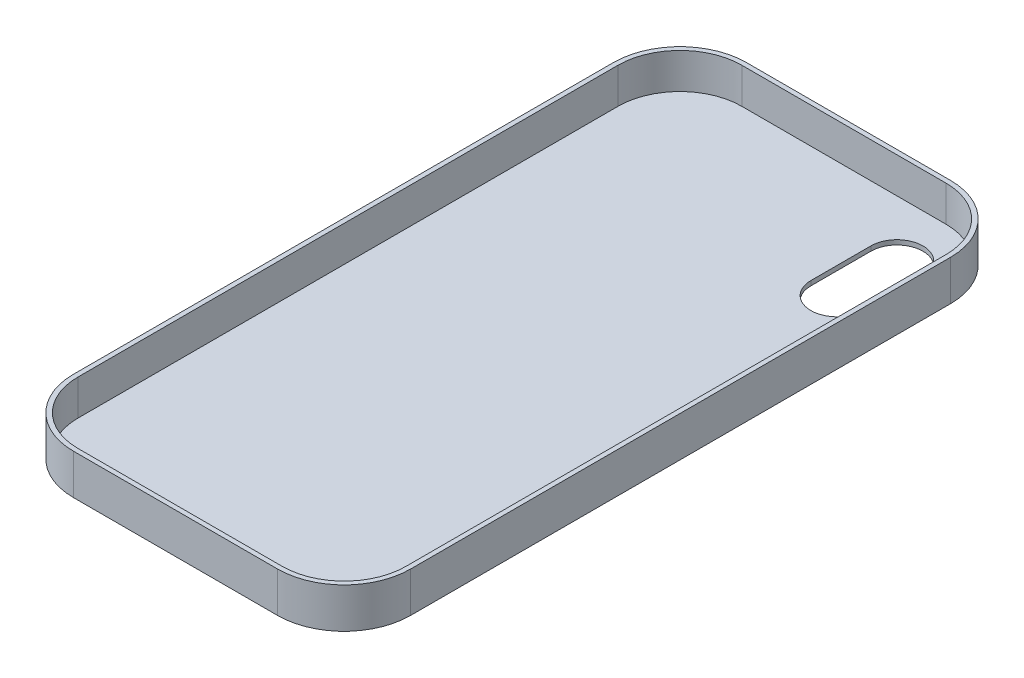
from build123d import *

# Parameters (mm, degrees)
BOSS_EXTRUDE1_DEPTH = 8.7
CUT_EXTRUDE1_DEPTH  = 7.7
CUT_EXTRUDE2_DEPTH  = 2


with BuildPart() as part:
    # Sketch1 → Boss-Extrude1 (new body)
    with BuildSketch(Plane(origin=(0, 0, 0), x_dir=(1, 0, 0), z_dir=(0, 1, 0))):
        with BuildLine():
            Line((-22.08, -72.785), (22.08, -72.785))
            ThreePointArc((22.08, -72.785), (32.255266581, -68.570266581), (36.47, -58.395))
            Line((36.47, -58.395), (36.47, 58.395))
            ThreePointArc((36.47, 58.395), (32.255266581, 68.570266581), (22.08, 72.785))
            Line((22.08, 72.785), (-22.08, 72.785))
            ThreePointArc((-22.08, 72.785), (-32.255266581, 68.570266581), (-36.47, 58.395))
            Line((-36.47, 58.395), (-36.47, -58.395))
            ThreePointArc((-36.47, -58.395), (-32.255266581, -68.570266581), (-22.08, -72.785))
        make_face()
    extrude(amount=BOSS_EXTRUDE1_DEPTH)

    # Sketch2 → Cut-Extrude1 (cut)
    with BuildSketch(Plane(origin=(0, 8.7, 0), x_dir=(1, 0, 0), z_dir=(0, 1, 0))):
        with BuildLine():
            Line((-22.08, -71.785), (22.08, -71.785))
            ThreePointArc((22.08, -71.785), (31.5481598, -67.8631598), (35.47, -58.395))
            Line((35.47, -58.395), (35.47, 58.395))
            ThreePointArc((35.47, 58.395), (31.5481598, 67.8631598), (22.08, 71.785))
            Line((22.08, 71.785), (-22.08, 71.785))
            ThreePointArc((-22.08, 71.785), (-31.5481598, 67.8631598), (-35.47, 58.395))
            Line((-35.47, 58.395), (-35.47, -58.395))
            ThreePointArc((-35.47, -58.395), (-31.5481598, -67.8631598), (-22.08, -71.785))
        make_face()
    extrude(amount=-CUT_EXTRUDE1_DEPTH, mode=Mode.SUBTRACT)

    # Sketch3 → Cut-Extrude2 (cut, through all)
    with BuildSketch(Plane(origin=(0, 1, 0), x_dir=(1, 0, 0), z_dir=(0, 1, 0))):
        with BuildLine():
            Line((29.28, 59.6), (29.28, 46.63))
            ThreePointArc((29.28, 46.63), (23.65, 41), (18.02, 46.63))
            Line((18.02, 46.63), (18.02, 59.6))
            ThreePointArc((18.02, 59.6), (23.65, 65.23), (29.28, 59.6))
        make_face()
    extrude(amount=-CUT_EXTRUDE2_DEPTH, mode=Mode.SUBTRACT)


solid = part.part
